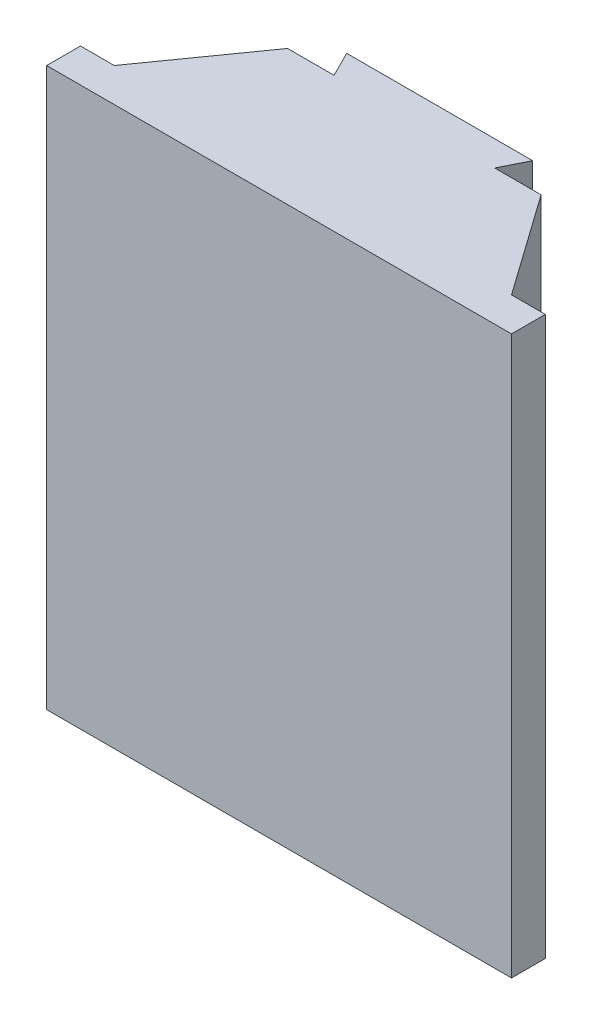
from build123d import *

# Parameters (mm, degrees)
BOSS_EXTRUDE1_DEPTH = 165


with BuildPart() as part:
    # Sketch1 → Boss-Extrude1 (new body, symmetric)
    with BuildSketch(Plane(origin=(0, 0, 0), x_dir=(1, 0, 0), z_dir=(0, 1, 0))):
        Polygon((-137.5, -156), (137.5, -156), (137.5, -136), (117.5, -136), (75, -76), (47.5, -76), (55, -61), (-55, -61), (-47.5, -76), (-75, -76), (-117.5, -136), (-137.5, -136), align=None)
    extrude(amount=BOSS_EXTRUDE1_DEPTH, both=True)


solid = part.part
